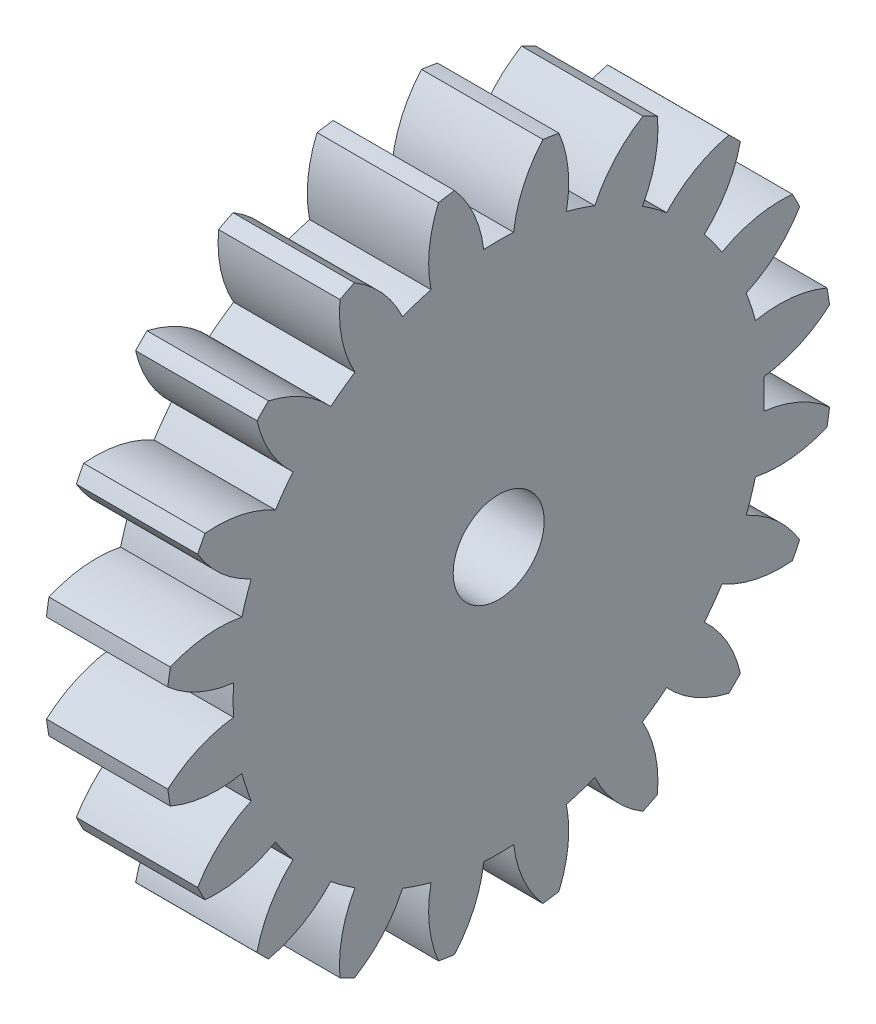
from build123d import *

# Parameters (mm, degrees)
BASPROSKE_W     = 20
BASPROSKE_H     = 55
TOOTHCUT_DEPTH  = 81.311892021
TEETHCUTS_COUNT = 20
TEETHCUTS_ANGLE = 342
BORSKE_R        = 7.5
BORE_DEPTH      = 50.0000508


with BuildPart() as part:
    # BasProSke → Base-Revolve (revolve)
    with BuildSketch(Plane(origin=(0, 0, 0), x_dir=(1, 0, 0), z_dir=(0, 1, 0))):
        with Locations((10, 27.5)):
            Rectangle(BASPROSKE_W, BASPROSKE_H)
    revolve(axis=Axis((-10, 0, 0), (1, 0, 0)))

    # TooCutSke → ToothCut (cut, through all)
    with BuildSketch(Plane(origin=(0, 0, 0), x_dir=(0, 0, -1), z_dir=(1, 0, 0))):
        with BuildLine():
            ThreePointArc((2.464838288, 43.679509764), (0, 43.749), (-2.464838288, 43.679509764))
            ThreePointArc((-2.464838288, 43.679509764), (-4.057398861, 49.476814676), (-7.300899231, 54.538899105))
            ThreePointArc((-7.300899231, 54.538899105), (0, 55.0254), (7.300899231, 54.538899105))
            ThreePointArc((7.300899231, 54.538899105), (4.057398861, 49.476814676), (2.464838288, 43.679509764))
        make_face()
    toothcut = extrude(amount=TOOTHCUT_DEPTH, mode=Mode.SUBTRACT)

    # TeethCuts: ToothCut ×20 about axis
    teethcuts_axis = Axis((-10, 0, 0), (1, 0, 0))
    for i in range(1, TEETHCUTS_COUNT):
        add(toothcut.rotate(teethcuts_axis, i * TEETHCUTS_ANGLE / (TEETHCUTS_COUNT - 1)), mode=Mode.SUBTRACT)

    # BorSke → Bore (cut, symmetric)
    with BuildSketch(Plane(origin=(0, 0, 0), x_dir=(0, 0, -1), z_dir=(1, 0, 0))):
        Circle(BORSKE_R)
    extrude(amount=BORE_DEPTH, both=True, mode=Mode.SUBTRACT)


solid = part.part
